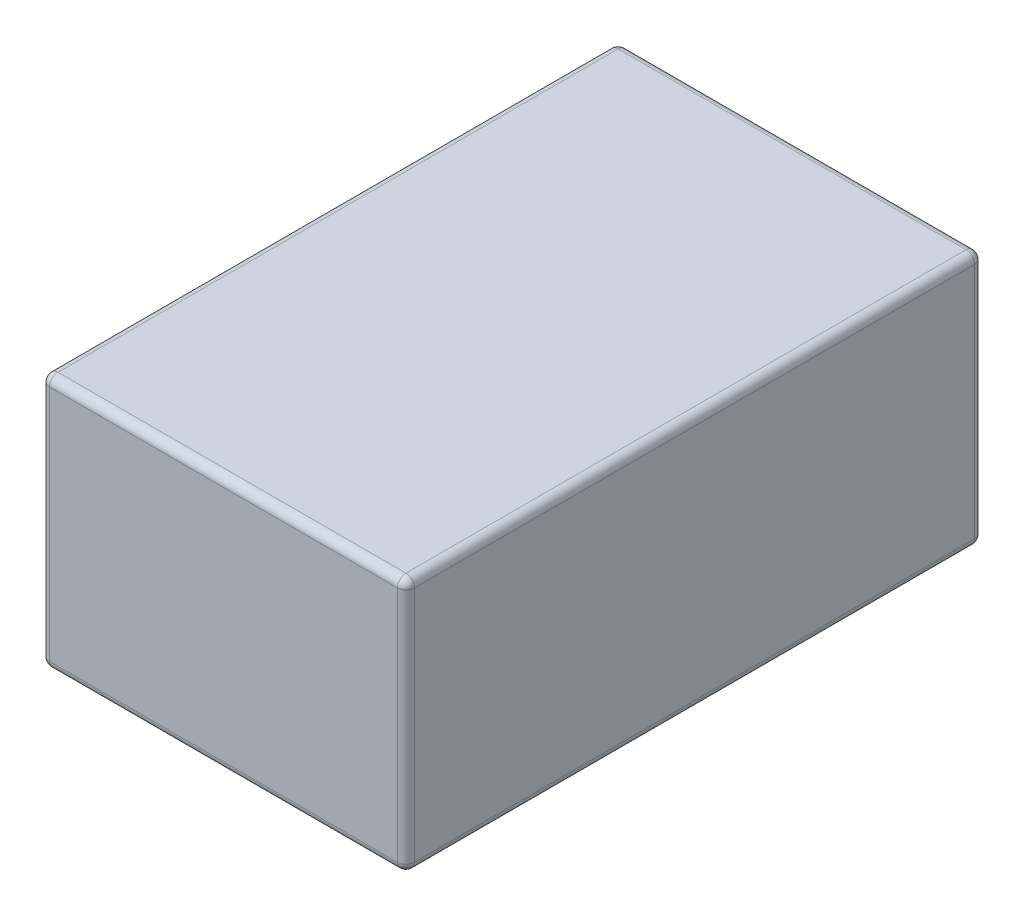
from build123d import *

# Parameters (mm, degrees)
SKETCH1_W           = 109.22
SKETCH1_H           = 76.2
BOSS_EXTRUDE1_DEPTH = 172.72
FILLET1_R           = 2.54


with BuildPart() as part:
    # Sketch1 → Boss-Extrude1 (new body)
    with BuildSketch(Plane.XY):
        with Locations((54.61, 38.1)):
            Rectangle(SKETCH1_W, SKETCH1_H)
    extrude(amount=BOSS_EXTRUDE1_DEPTH)

    # Fillet1
    fillet1_edges = [part.edges().sort_by_distance(p)[0] for p in [
        (109.22, 38.1, 172.72),
        (54.61, 76.2, 172.72),
        (0, 38.1, 172.72),
        (54.61, 76.2, 0),
        (109.22, 38.1, 0),
        (54.61, 0, 0),
        (0, 38.1, 0),
        (0, 76.2, 86.36),
        (109.22, 76.2, 86.36),
        (109.22, 0, 86.36),
        (0, 0, 86.36),
        (54.61, 0, 172.72),
    ]]
    fillet(fillet1_edges, radius=FILLET1_R)


solid = part.part
